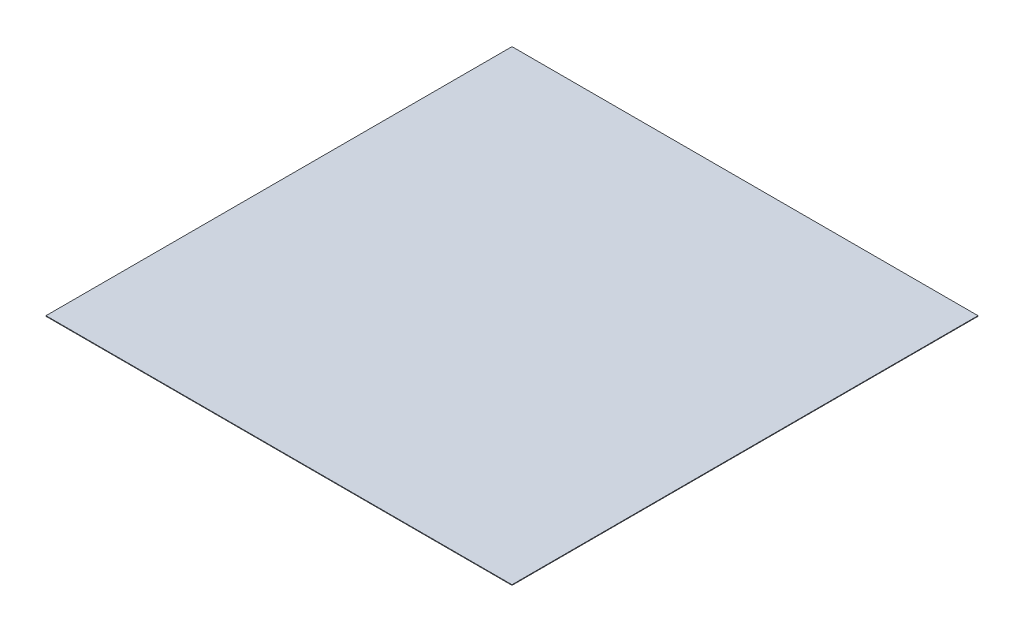
from build123d import *

# Parameters (mm, degrees)
SKETCH1_W           = 800
SKETCH1_H           = 800
BOSS_EXTRUDE1_DEPTH = 1


with BuildPart() as part:
    # Sketch1 → Boss-Extrude1 (new body)
    with BuildSketch(Plane(origin=(0, 0, 0), x_dir=(1, 0, 0), z_dir=(0, 1, 0))):
        with Locations((8.586012697, -28.482972136)):
            Rectangle(SKETCH1_W, SKETCH1_H)
    extrude(amount=BOSS_EXTRUDE1_DEPTH)


solid = part.part
